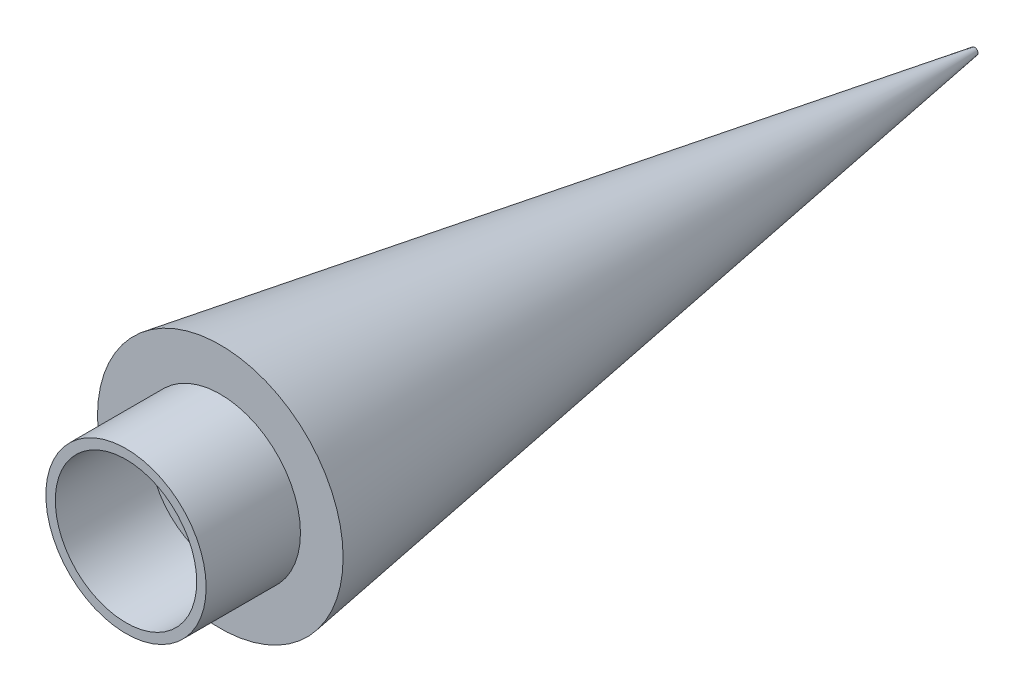
from build123d import *

# Parameters (mm, degrees)
SKETCH1_R           = 8.5
SKETCH1_R_2         = 7.5
EXTRUDE_THIN1_DEPTH = 10
SKETCH2_R           = 13.024850754
BOSS_EXTRUDE1_DEPTH = 80
BOSS_EXTRUDE1_TAPER = 9
SCALE1_SCALE        = 10
SCALE2_SCALE        = 0.75


with BuildPart() as part:
    # Sketch1 → Extrude-Thin1 (new body)
    with BuildSketch(Plane.XY):
        Circle(SKETCH1_R)
        Circle(SKETCH1_R_2, mode=Mode.SUBTRACT)
    extrude(amount=EXTRUDE_THIN1_DEPTH)

    # Sketch2 → Boss-Extrude1 (add)
    with BuildSketch(Plane(origin=(0, 0, 0), x_dir=(-1, 0, 0), z_dir=(0, 0, -1))):
        Circle(SKETCH2_R)
    extrude(amount=BOSS_EXTRUDE1_DEPTH, taper=BOSS_EXTRUDE1_TAPER)


with BuildPart() as part_1:
    # Scale1: scaled about (0, 0, 0)
    add(part.part.scale(SCALE1_SCALE))


with BuildPart() as part_2:
    # Scale2: scaled about (0, 0, 0)
    add(part_1.part.scale(SCALE2_SCALE))


solid = part_2.part
